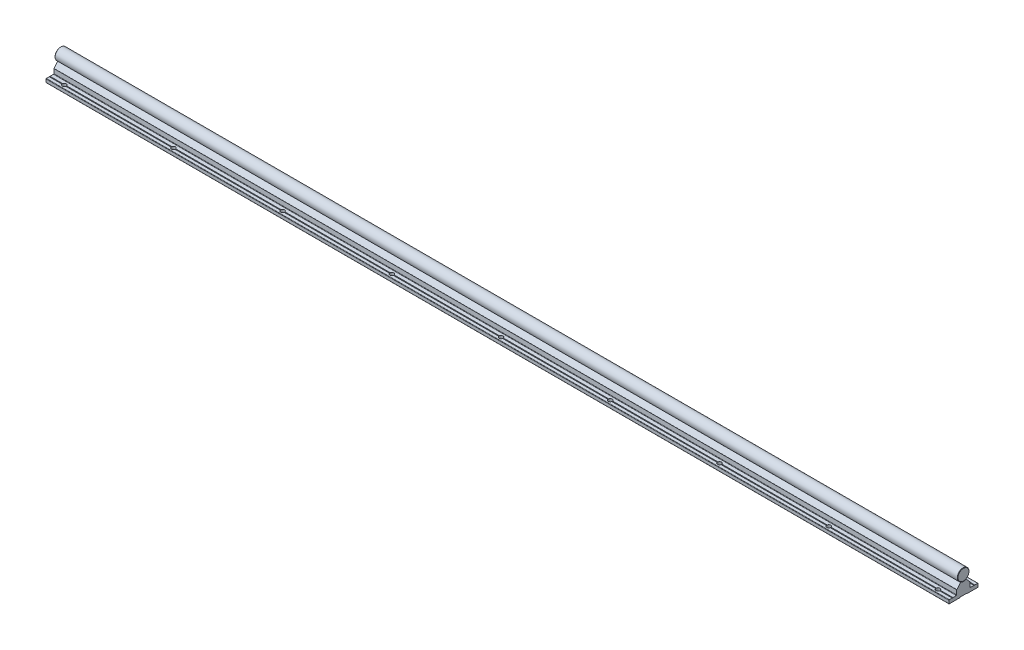
from build123d import *

# Parameters (mm, degrees)
EXTRUDE_2614_DEPTH       = 1500
SKETCH_1_3_R             = 8
EXTRUDE_2743_DEPTH       = 1500
FILLET_4_R               = 0.2
SKETCH_2_R               = 2.75
CUT_EXTRUDE_1_DEPTH      = 6
PATTERN_LINEAR_1_COUNT   = 20
PATTERN_LINEAR_1_PITCH   = 150
PATTERN_LINEAR_2_COUNT   = 20
PATTERN_LINEAR_2_PITCH   = 150
FILLET_1_R               = 0.3
CUT_EXTRUDE_2_DEPTH      = 3
FILLET_2_R               = 0.3
PATTERN_LINEAR_3_COUNT   = 20
PATTERN_LINEAR_3_PITCH   = 150
CHAMFER_1_SIZE           = 0.5
FILLET_3_R               = 0.5
FILLET_5_R               = 0.2
FILLET_6_R               = 0.1
FILLET_7_R               = 0.1
SKETCH_7_W               = 3500
SKETCH_7_H               = 1500
SKETCH_7_W_2             = 1240
SKETCH_7_H_2             = 500
CUT_EXTRUDE_3_DEPTH      = 9.0000001
CUT_EXTRUDE_3_DEPTH_BACK = 26.0000001
CHAMFER_2_SIZE           = 0.5


with BuildPart() as part:
    # Sketch 1 → Extrude 2614 (new body, symmetric)
    with BuildSketch(Plane(origin=(0, 0, 0), x_dir=(0, 0, -1), z_dir=(1, 0, 0))):
        Polygon((-20, -25), (-4.75, -25), (-4.75, -24.4), (4.75, -24.4), (4.75, -25), (20, -25), (20, -20), (15.5, -20), (15, -20.5), (14.5, -20), (9.25, -20), (9.25, -13.3), (9.110116754, -13.3), (4, -7.21), (3.8, -7.21), (2.309327639, -7.659439004), (0, -8.355703281), (-2.309327657, -7.659438999), (-3.8, -7.21), (-4, -7.21), (-9.110116754, -13.3), (-9.25, -13.3), (-9.25, -20), (-14.5, -20), (-15, -20.5), (-15.5, -20), (-20, -20), align=None)
    extrude(amount=EXTRUDE_2614_DEPTH, both=True)

    # Fillet 4
    fillet_4_edges = [part.edges().sort_by_distance(p)[0] for p in [
        (0, -20, -15.5),
        (0, -24.4, -4.75),
        (0, -24.4, 4.75),
        (0, -20, 15.5),
        (0, -20, 14.5),
        (0, -8.355703281, 0),
        (0, -20, -14.5),
    ]]
    fillet(fillet_4_edges, radius=FILLET_4_R)

    # Sketch 2 → Cut-Extrude 1 (cut, through all)
    with BuildSketch(Plane(origin=(0, -20, 0), x_dir=(1, 0, 0), z_dir=(0, 1, 0))):
        with Locations((-1425, -15)):
            Circle(SKETCH_2_R)
        with Locations((-1425, 15)):
            Circle(SKETCH_2_R)
        with Locations((-1275, -15)):
            Circle(SKETCH_2_R)
        with Locations((-1275, 15)):
            Circle(SKETCH_2_R)
        with Locations((-1125, -15)):
            Circle(SKETCH_2_R)
        with Locations((-1125, 15)):
            Circle(SKETCH_2_R)
        with Locations((-975, -15)):
            Circle(SKETCH_2_R)
        with Locations((-975, 15)):
            Circle(SKETCH_2_R)
        with Locations((-825, -15)):
            Circle(SKETCH_2_R)
        with Locations((-825, 15)):
            Circle(SKETCH_2_R)
        with Locations((-675, -15)):
            Circle(SKETCH_2_R)
        with Locations((-675, 15)):
            Circle(SKETCH_2_R)
        with Locations((-525, -15)):
            Circle(SKETCH_2_R)
        with Locations((-525, 15)):
            Circle(SKETCH_2_R)
        with Locations((-375, -15)):
            Circle(SKETCH_2_R)
        with Locations((-375, 15)):
            Circle(SKETCH_2_R)
        with Locations((-225, -15)):
            Circle(SKETCH_2_R)
        with Locations((-225, 15)):
            Circle(SKETCH_2_R)
        with Locations((-75, -15)):
            Circle(SKETCH_2_R)
        with Locations((-75, 15)):
            Circle(SKETCH_2_R)
        with Locations((75, -15)):
            Circle(SKETCH_2_R)
        with Locations((75, 15)):
            Circle(SKETCH_2_R)
        with Locations((225, -15)):
            Circle(SKETCH_2_R)
        with Locations((225, 15)):
            Circle(SKETCH_2_R)
        with Locations((375, -15)):
            Circle(SKETCH_2_R)
        with Locations((375, 15)):
            Circle(SKETCH_2_R)
        with Locations((525, -15)):
            Circle(SKETCH_2_R)
        with Locations((525, 15)):
            Circle(SKETCH_2_R)
        with Locations((675, -15)):
            Circle(SKETCH_2_R)
        with Locations((675, 15)):
            Circle(SKETCH_2_R)
        with Locations((825, -15)):
            Circle(SKETCH_2_R)
        with Locations((825, 15)):
            Circle(SKETCH_2_R)
        with Locations((975, -15)):
            Circle(SKETCH_2_R)
        with Locations((975, 15)):
            Circle(SKETCH_2_R)
        with Locations((1125, -15)):
            Circle(SKETCH_2_R)
        with Locations((1125, 15)):
            Circle(SKETCH_2_R)
        with Locations((1275, -15)):
            Circle(SKETCH_2_R)
        with Locations((1275, 15)):
            Circle(SKETCH_2_R)
        with Locations((1425, -15)):
            Circle(SKETCH_2_R)
        with Locations((1425, 15)):
            Circle(SKETCH_2_R)
    extrude(amount=-CUT_EXTRUDE_1_DEPTH, mode=Mode.SUBTRACT)

    # Sketch 3 → Cut-Revolve 1 (revolve, cut)
    with BuildSketch(Plane.XY):
        Polygon((-1425, 0), (-1427.2, -1.270170592), (-1427.2, -7.5), (-1427.75, -7.5), (-1427.75, -19), (-1429.75, -19), (-1429.75, -24.4), (-1425, -24.4), align=None)
    cut_revolve_1 = revolve(axis=Axis((-1425, 56.434869358, 0), (0, -1, 0)), mode=Mode.SUBTRACT)

    # Pattern Linear 1: Cut-Revolve 1 ×20
    with Locations(*[(i * PATTERN_LINEAR_1_PITCH, 0, 0) for i in range(1, PATTERN_LINEAR_1_COUNT)]):
        add(cut_revolve_1, mode=Mode.SUBTRACT)

    # Fillet 3
    fillet_3_edges = [part.edges().sort_by_distance(p)[0] for p in [
        (0, -20, -9.25),
        (0, -20, -20),
        (0, -25, -20),
        (0, -25, -4.75),
        (0, -25, 4.75),
        (0, -20, 9.25),
        (0, -25, 20),
        (0, -20, 20),
    ]]
    fillet(fillet_3_edges, radius=FILLET_3_R)

    # Fillet 5
    fillet_5_edges = [part.edges().sort_by_distance(p)[0] for p in [
        (0, -7.21, 4),
        (0, -7.21, 3.8),
        (0, -7.21, -3.8),
        (0, -7.21, -4),
    ]]
    fillet(fillet_5_edges, radius=FILLET_5_R)

    # Fillet 6
    fillet_6_edges = [part.edges().sort_by_distance(p)[0] for p in [
        (0, -13.3, 9.25),
        (0, -13.3, -9.25),
    ]]
    fillet(fillet_6_edges, radius=FILLET_6_R)

    # Fillet 7
    fillet_7_edges = [part.edges().sort_by_distance(p)[0] for p in [
        (0, -13.3, 9.110116754),
        (0, -13.3, -9.110116754),
    ]]
    fillet(fillet_7_edges, radius=FILLET_7_R)


with BuildPart() as body_2:
    # Sketch 1_3 → Extrude 2743 (new body, symmetric)
    with BuildSketch(Plane(origin=(0, 0, 0), x_dir=(0, 0, -1), z_dir=(1, 0, 0))):
        Circle(SKETCH_1_3_R)
    extrude(amount=EXTRUDE_2743_DEPTH, both=True)

    # Sketch 4 → Cut-Revolve 2 (revolve, cut)
    with BuildSketch(Plane.XY):
        Polygon((-1425, -10), (-1427.2, -10), (-1427.2, -1.270170592), (-1425, 0), align=None)
    cut_revolve_2 = revolve(axis=Axis((-1425, 39.840222878, 0), (0, -1, 0)), mode=Mode.SUBTRACT)

    # Pattern Linear 2: Cut-Revolve 2 ×20
    with Locations(*[(i * PATTERN_LINEAR_2_PITCH, 0, 0) for i in range(1, PATTERN_LINEAR_2_COUNT)]):
        add(cut_revolve_2, mode=Mode.SUBTRACT)

    # Chamfer 1
    chamfer_1_edges = [body_2.edges().sort_by_distance(p)[0] for p in [
        (-1500, 0, 8),
        (1500, 0, 8),
    ]]
    chamfer(chamfer_1_edges, length=CHAMFER_1_SIZE)


with BuildPart() as body_3:
    # Sketch 5 → Revolve 1 (revolve)
    with BuildSketch(Plane.XY):
        Polygon((-1425, -24), (-1429.5, -24), (-1429.5, -19), (-1427.5, -19), (-1427.5, -2.461880215), (-1426.7, -2), (-1425, -2), align=None)
    revolve(axis=Axis((-1425, 35.529626596, 0), (0, -1, 0)))

    # Fillet 1
    fillet_1_edges = [body_3.edges().sort_by_distance(p)[0] for p in [
        (-1420.5, -19, 0),
    ]]
    fillet(fillet_1_edges, radius=FILLET_1_R)

    # Sketch 6 → Cut-Extrude 2 (cut)
    with BuildSketch(Plane.XZ.offset(24)):
        Polygon((-1423.25, -1.010362971), (-1423.25, 1.010362971), (-1425, 2.020725942), (-1426.75, 1.010362971), (-1426.75, -1.010362971), (-1425, -2.020725942), align=None)
    extrude(amount=-CUT_EXTRUDE_2_DEPTH, mode=Mode.SUBTRACT)

    # Fillet 2
    fillet_2_edges = [body_3.edges().sort_by_distance(p)[0] for p in [
        (-1424.125, -24, -1.515544457),
        (-1423.25, -24, 0),
        (-1424.125, -24, 1.515544457),
        (-1425.875, -24, 1.515544457),
        (-1426.75, -24, 0),
        (-1425.875, -24, -1.515544457),
        (-1420.5, -24, 0),
    ]]
    fillet(fillet_2_edges, radius=FILLET_2_R)


with BuildPart() as pattern_linear_3_1:
    # Pattern Linear 3: pattern copy
    add(body_3.part.moved(Location(Vector(1, 0, 0) * (1 * PATTERN_LINEAR_3_PITCH))))


with BuildPart() as pattern_linear_3_2:
    # Pattern Linear 3: pattern copy
    add(body_3.part.moved(Location(Vector(1, 0, 0) * (2 * PATTERN_LINEAR_3_PITCH))))


with BuildPart() as pattern_linear_3_3:
    # Pattern Linear 3: pattern copy
    add(body_3.part.moved(Location(Vector(1, 0, 0) * (3 * PATTERN_LINEAR_3_PITCH))))


with BuildPart() as pattern_linear_3_4:
    # Pattern Linear 3: pattern copy
    add(body_3.part.moved(Location(Vector(1, 0, 0) * (4 * PATTERN_LINEAR_3_PITCH))))


with BuildPart() as pattern_linear_3_5:
    # Pattern Linear 3: pattern copy
    add(body_3.part.moved(Location(Vector(1, 0, 0) * (5 * PATTERN_LINEAR_3_PITCH))))


with BuildPart() as pattern_linear_3_6:
    # Pattern Linear 3: pattern copy
    add(body_3.part.moved(Location(Vector(1, 0, 0) * (6 * PATTERN_LINEAR_3_PITCH))))


with BuildPart() as pattern_linear_3_7:
    # Pattern Linear 3: pattern copy
    add(body_3.part.moved(Location(Vector(1, 0, 0) * (7 * PATTERN_LINEAR_3_PITCH))))


with BuildPart() as pattern_linear_3_8:
    # Pattern Linear 3: pattern copy
    add(body_3.part.moved(Location(Vector(1, 0, 0) * (8 * PATTERN_LINEAR_3_PITCH))))


with BuildPart() as pattern_linear_3_9:
    # Pattern Linear 3: pattern copy
    add(body_3.part.moved(Location(Vector(1, 0, 0) * (9 * PATTERN_LINEAR_3_PITCH))))


with BuildPart() as pattern_linear_3_10:
    # Pattern Linear 3: pattern copy
    add(body_3.part.moved(Location(Vector(1, 0, 0) * (10 * PATTERN_LINEAR_3_PITCH))))


with BuildPart() as pattern_linear_3_11:
    # Pattern Linear 3: pattern copy
    add(body_3.part.moved(Location(Vector(1, 0, 0) * (11 * PATTERN_LINEAR_3_PITCH))))


with BuildPart() as pattern_linear_3_12:
    # Pattern Linear 3: pattern copy
    add(body_3.part.moved(Location(Vector(1, 0, 0) * (12 * PATTERN_LINEAR_3_PITCH))))


with BuildPart() as pattern_linear_3_13:
    # Pattern Linear 3: pattern copy
    add(body_3.part.moved(Location(Vector(1, 0, 0) * (13 * PATTERN_LINEAR_3_PITCH))))


with BuildPart() as pattern_linear_3_14:
    # Pattern Linear 3: pattern copy
    add(body_3.part.moved(Location(Vector(1, 0, 0) * (14 * PATTERN_LINEAR_3_PITCH))))


with BuildPart() as pattern_linear_3_15:
    # Pattern Linear 3: pattern copy
    add(body_3.part.moved(Location(Vector(1, 0, 0) * (15 * PATTERN_LINEAR_3_PITCH))))


with BuildPart() as pattern_linear_3_16:
    # Pattern Linear 3: pattern copy
    add(body_3.part.moved(Location(Vector(1, 0, 0) * (16 * PATTERN_LINEAR_3_PITCH))))


with BuildPart() as pattern_linear_3_17:
    # Pattern Linear 3: pattern copy
    add(body_3.part.moved(Location(Vector(1, 0, 0) * (17 * PATTERN_LINEAR_3_PITCH))))


with BuildPart() as pattern_linear_3_18:
    # Pattern Linear 3: pattern copy
    add(body_3.part.moved(Location(Vector(1, 0, 0) * (18 * PATTERN_LINEAR_3_PITCH))))


with BuildPart() as pattern_linear_3_19:
    # Pattern Linear 3: pattern copy
    add(body_3.part.moved(Location(Vector(1, 0, 0) * (19 * PATTERN_LINEAR_3_PITCH))))


with BuildPart() as cut_extrude_3_tool:
    # Sketch 7 → Cut-Extrude 3 (new body, two sides)
    with BuildSketch(Plane(origin=(0, 0, 0), x_dir=(1, 0, 0), z_dir=(0, 1, 0))) as cut_extrude_3_sk:
        Rectangle(SKETCH_7_W, SKETCH_7_H)
        with Locations((825, 0)):
            Rectangle(SKETCH_7_W_2, SKETCH_7_H_2, mode=Mode.SUBTRACT)
    extrude(amount=CUT_EXTRUDE_3_DEPTH)
    extrude(cut_extrude_3_sk.sketch, amount=-CUT_EXTRUDE_3_DEPTH_BACK)


with BuildPart() as part_1:
    add(part.part)

    # Cut-Extrude 3: cut by cut_extrude_3_tool
    add(cut_extrude_3_tool.part, mode=Mode.SUBTRACT)


with BuildPart() as body_2_1:
    add(body_2.part)

    # Cut-Extrude 3: cut by cut_extrude_3_tool
    add(cut_extrude_3_tool.part, mode=Mode.SUBTRACT)

    # Chamfer 2
    chamfer_2_edges = [body_2_1.edges().sort_by_distance(p)[0] for p in [
        (205, 0, 8),
        (1445, 0, 8),
    ]]
    chamfer(chamfer_2_edges, length=CHAMFER_2_SIZE)


with BuildPart() as body_3_1:
    add(body_3.part)

    # Cut-Extrude 3: cut by cut_extrude_3_tool
    add(cut_extrude_3_tool.part, mode=Mode.SUBTRACT)


with BuildPart() as pattern_linear_3_1_1:
    add(pattern_linear_3_1.part)

    # Cut-Extrude 3: cut by cut_extrude_3_tool
    add(cut_extrude_3_tool.part, mode=Mode.SUBTRACT)


with BuildPart() as pattern_linear_3_2_1:
    add(pattern_linear_3_2.part)

    # Cut-Extrude 3: cut by cut_extrude_3_tool
    add(cut_extrude_3_tool.part, mode=Mode.SUBTRACT)


with BuildPart() as pattern_linear_3_3_1:
    add(pattern_linear_3_3.part)

    # Cut-Extrude 3: cut by cut_extrude_3_tool
    add(cut_extrude_3_tool.part, mode=Mode.SUBTRACT)


with BuildPart() as pattern_linear_3_4_1:
    add(pattern_linear_3_4.part)

    # Cut-Extrude 3: cut by cut_extrude_3_tool
    add(cut_extrude_3_tool.part, mode=Mode.SUBTRACT)


with BuildPart() as pattern_linear_3_5_1:
    add(pattern_linear_3_5.part)

    # Cut-Extrude 3: cut by cut_extrude_3_tool
    add(cut_extrude_3_tool.part, mode=Mode.SUBTRACT)


with BuildPart() as pattern_linear_3_6_1:
    add(pattern_linear_3_6.part)

    # Cut-Extrude 3: cut by cut_extrude_3_tool
    add(cut_extrude_3_tool.part, mode=Mode.SUBTRACT)


with BuildPart() as pattern_linear_3_7_1:
    add(pattern_linear_3_7.part)

    # Cut-Extrude 3: cut by cut_extrude_3_tool
    add(cut_extrude_3_tool.part, mode=Mode.SUBTRACT)


with BuildPart() as pattern_linear_3_8_1:
    add(pattern_linear_3_8.part)

    # Cut-Extrude 3: cut by cut_extrude_3_tool
    add(cut_extrude_3_tool.part, mode=Mode.SUBTRACT)


with BuildPart() as pattern_linear_3_9_1:
    add(pattern_linear_3_9.part)

    # Cut-Extrude 3: cut by cut_extrude_3_tool
    add(cut_extrude_3_tool.part, mode=Mode.SUBTRACT)


with BuildPart() as pattern_linear_3_10_1:
    add(pattern_linear_3_10.part)

    # Cut-Extrude 3: cut by cut_extrude_3_tool
    add(cut_extrude_3_tool.part, mode=Mode.SUBTRACT)


solid = Compound([pattern_linear_3_11.part, pattern_linear_3_12.part, pattern_linear_3_13.part, pattern_linear_3_14.part, pattern_linear_3_15.part, pattern_linear_3_16.part, pattern_linear_3_17.part, pattern_linear_3_18.part, pattern_linear_3_19.part, part_1.part, body_2_1.part])
